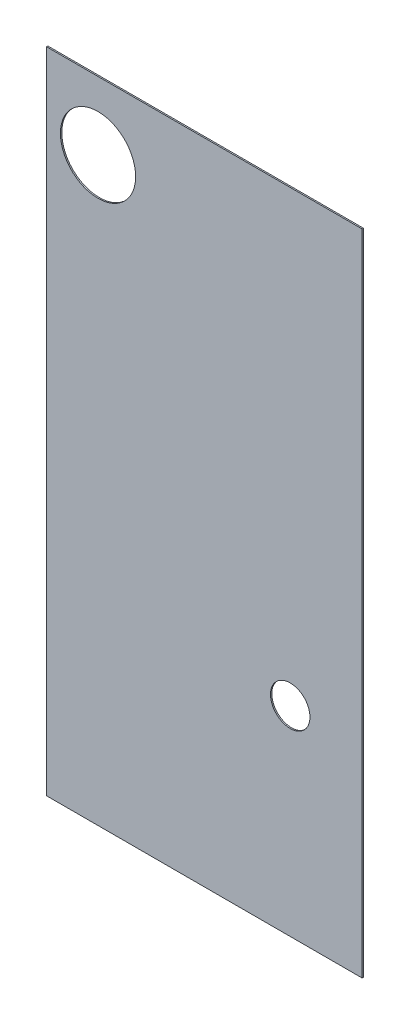
from build123d import *

# Parameters (mm, degrees)
SKETCH1_W               = 605.082945164
SKETCH1_H               = 1243.943840666
BOSS_EXTRUDE1_DEPTH     = 2.54
SKETCH3_R               = 72.07245037
SKETCH3_R_2             = 37.854305462
CUT_EXTRUDE1_DEPTH      = 1
CUT_EXTRUDE1_DEPTH_BACK = 3.54


with BuildPart() as part:
    # Sketch1 → Boss-Extrude1 (new body)
    with BuildSketch(Plane.XY):
        with Locations((-316.280332246, 820.569825563)):
            Rectangle(SKETCH1_W, SKETCH1_H)
    extrude(amount=BOSS_EXTRUDE1_DEPTH)

    # Sketch3 → Cut-Extrude1 (cut, two sides)
    with BuildSketch(Plane.XY.offset(2.54)) as cut_extrude1_sk:
        with Locations((-520.126168734, 1312.226670832)):
            Circle(SKETCH3_R)
        with Locations((-151.601482637, 581.817383071)):
            Circle(SKETCH3_R_2)
    extrude(amount=CUT_EXTRUDE1_DEPTH, mode=Mode.SUBTRACT)
    extrude(cut_extrude1_sk.sketch, amount=-CUT_EXTRUDE1_DEPTH_BACK, mode=Mode.SUBTRACT)


solid = part.part
